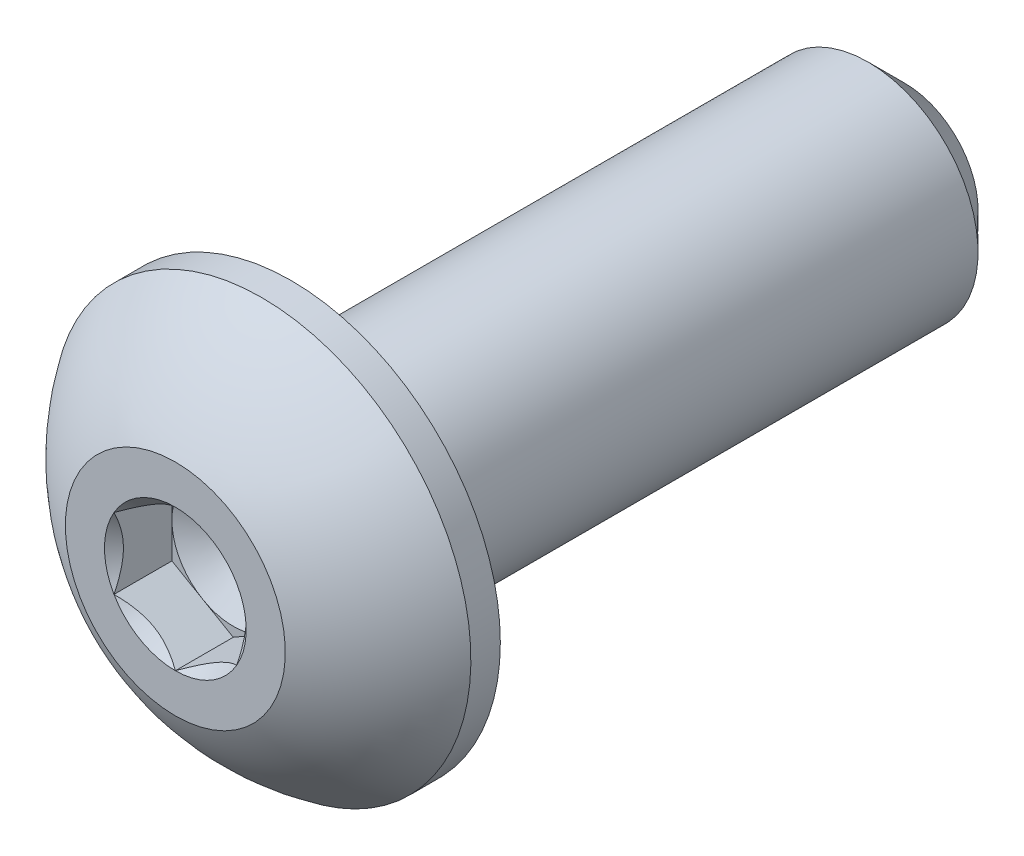
from build123d import *

# Parameters (mm, degrees)
SKETCH1_W          = 7.9375
SKETCH1_H          = 1.4224
CHAMFER1_SIZE      = 0.47625
SKETCH4_R          = 2.7051
EXTRUDE1_DEPTH     = 1.4986
CUT_EXTRUDE1_DEPTH = 0.7493
SKETCH7_R          = 0.916543552
CUT_EXTRUDE4_DEPTH = 0.7493
CUT_EXTRUDE4_TAPER = 45
SKETCH8_R          = 0.79375
CUT_EXTRUDE5_DEPTH = 0.249766667
CUT_EXTRUDE5_TAPER = 60


with BuildPart() as part:
    # Sketch1 → Revolve1 (revolve)
    with BuildSketch(Plane(origin=(0, 0, 0), x_dir=(0, 0, -1), z_dir=(1, 0, 0))):
        with Locations((3.96875, 0.7112)):
            Rectangle(SKETCH1_W, SKETCH1_H)
    revolve(axis=Axis((0, 0, 0), (0, 0, 1)))

    # Chamfer1
    chamfer1_edges = [part.edges().sort_by_distance(p)[0] for p in [
        (0, -1.4224, -7.9375),
    ]]
    chamfer(chamfer1_edges, length=CHAMFER1_SIZE)

    # Sketch4 → Extrude1 (add)
    with BuildSketch(Plane.XY):
        Circle(SKETCH4_R)
    extrude(amount=EXTRUDE1_DEPTH)

    # Sketch9 → Cut-Revolve3 (revolve, cut)
    with BuildSketch(Plane(origin=(0, 0, 0), x_dir=(0, 0, -1), z_dir=(1, 0, 0))):
        with BuildLine():
            Line((0, 2.7051), (-0.381, 2.7051))
            ThreePointArc((-0.381, 2.7051), (-1.025093234, 2.138064897), (-1.4986, 1.4224))
            Line((-1.4986, 1.4224), (-1.8796, 1.4224))
            Line((-1.8796, 1.4224), (-1.8796, 3.0861))
            Line((-1.8796, 3.0861), (0, 3.0861))
            Line((0, 3.0861), (0, 2.7051))
        make_face()
    revolve(axis=Axis((0, 0, 0), (0, 0, 1)), mode=Mode.SUBTRACT)

    # Sketch6 → Cut-Extrude1 (cut)
    with BuildSketch(Plane.XY.offset(1.4986)):
        Polygon((0, -0.916543552), (0.79375, -0.458271776), (0.79375, 0.458271776), (0, 0.916543552), (-0.79375, 0.458271776), (-0.79375, -0.458271776), align=None)
    extrude(amount=-CUT_EXTRUDE1_DEPTH, mode=Mode.SUBTRACT)

    # Sketch7 → Cut-Extrude4 (cut)
    with BuildSketch(Plane.XY.offset(1.4986)):
        Circle(SKETCH7_R)
    extrude(amount=-CUT_EXTRUDE4_DEPTH, taper=CUT_EXTRUDE4_TAPER, mode=Mode.SUBTRACT)

    # Sketch8 → Cut-Extrude5 (cut)
    with BuildSketch(Plane.XY.offset(0.7493)):
        Circle(SKETCH8_R)
    extrude(amount=-CUT_EXTRUDE5_DEPTH, taper=CUT_EXTRUDE5_TAPER, mode=Mode.SUBTRACT)


solid = part.part
